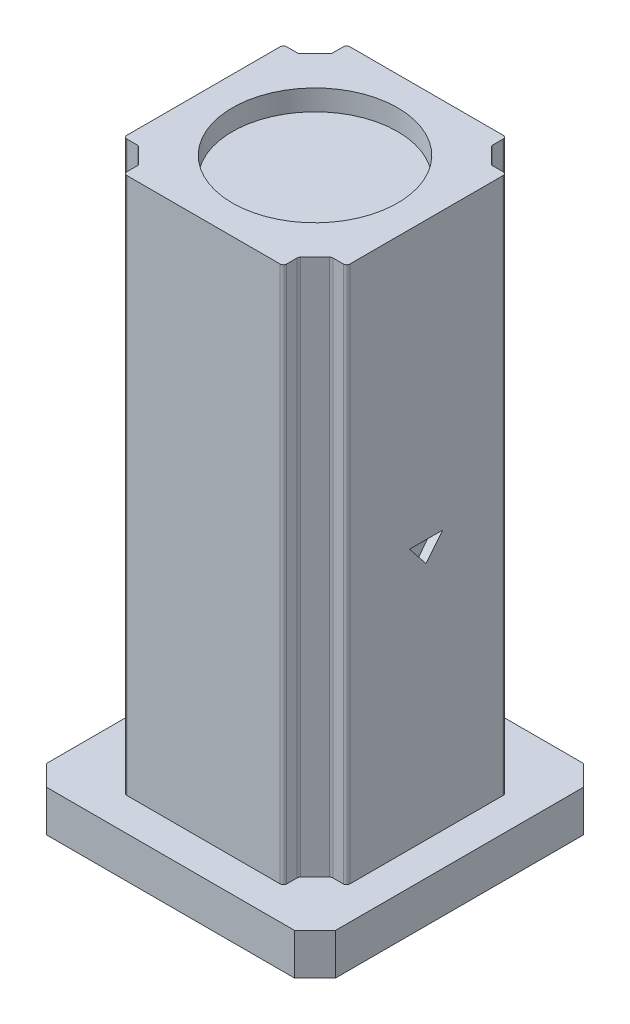
from build123d import *

# Parameters (mm, degrees)
BOSS_EXTRUDE1_DEPTH = 10
BOSS_EXTRUDE2_DEPTH = 130
FILLET1_R           = 0.8
SKETCH3_R           = 20
CUT_EXTRUDE1_DEPTH  = 5
CUT_EXTRUDE2_DEPTH  = 2


with BuildPart() as part:
    # Sketch1 → Boss-Extrude1 (new body)
    with BuildSketch(Plane(origin=(0, 0, 0), x_dir=(1, 0, 0), z_dir=(0, 1, 0))):
        Polygon((-35, 30), (-30, 35), (30, 35), (35, 30), (35, -30), (30, -35), (-30, -35), (-35, -30), align=None)
    extrude(amount=BOSS_EXTRUDE1_DEPTH)

    # Sketch2 → Boss-Extrude2 (add)
    with BuildSketch(Plane(origin=(0, 10, 0), x_dir=(1, 0, 0), z_dir=(0, 1, 0))):
        Polygon((-23.343145751, 19.343145751), (-19.343145751, 23.343145751), (-19.343145751, 27), (19.343145751, 27), (19.343145751, 23.343145751), (23.343145751, 19.343145751), (27, 19.343145751), (27, -19.343145751), (23.343145751, -19.343145751), (19.343145751, -23.343145751), (19.343145751, -27), (-19.343145751, -27), (-19.343145751, -23.343145751), (-23.343145751, -19.343145751), (-27, -19.343145751), (-27, 19.343145751), align=None)
    extrude(amount=BOSS_EXTRUDE2_DEPTH)

    # Fillet1
    fillet1_edges = [part.edges().sort_by_distance(p)[0] for p in [
        (27, 75, 19.343145751),
        (27, 75, -19.343145751),
        (23.343145751, 75, -19.343145751),
        (19.343145751, 75, -23.343145751),
        (19.343145751, 75, -27),
        (-19.343145751, 75, -27),
        (-19.343145751, 75, -23.343145751),
        (-23.343145751, 75, -19.343145751),
        (-27, 75, -19.343145751),
        (-27, 75, 19.343145751),
        (-23.343145751, 75, 19.343145751),
        (-19.343145751, 75, 23.343145751),
        (-19.343145751, 75, 27),
        (19.343145751, 75, 27),
        (19.343145751, 75, 23.343145751),
        (23.343145751, 75, 19.343145751),
    ]]
    fillet(fillet1_edges, radius=FILLET1_R)

    # Sketch3 → Cut-Extrude1 (cut)
    with BuildSketch(Plane(origin=(0, 140, 0), x_dir=(1, 0, 0), z_dir=(0, 1, 0))):
        Circle(SKETCH3_R)
    extrude(amount=-CUT_EXTRUDE1_DEPTH, mode=Mode.SUBTRACT)

    # Sketch5 → Cut-Extrude2 (cut)
    with BuildSketch(Plane(origin=(27, 0, 0), x_dir=(0, 0, -1), z_dir=(1, 0, 0))):
        Polygon((-4.112253732, 72.96796578), (3.887746268, 72.96796578), (-0.112253732, 67.96796578), align=None)
    extrude(amount=-CUT_EXTRUDE2_DEPTH, mode=Mode.SUBTRACT)


solid = part.part
